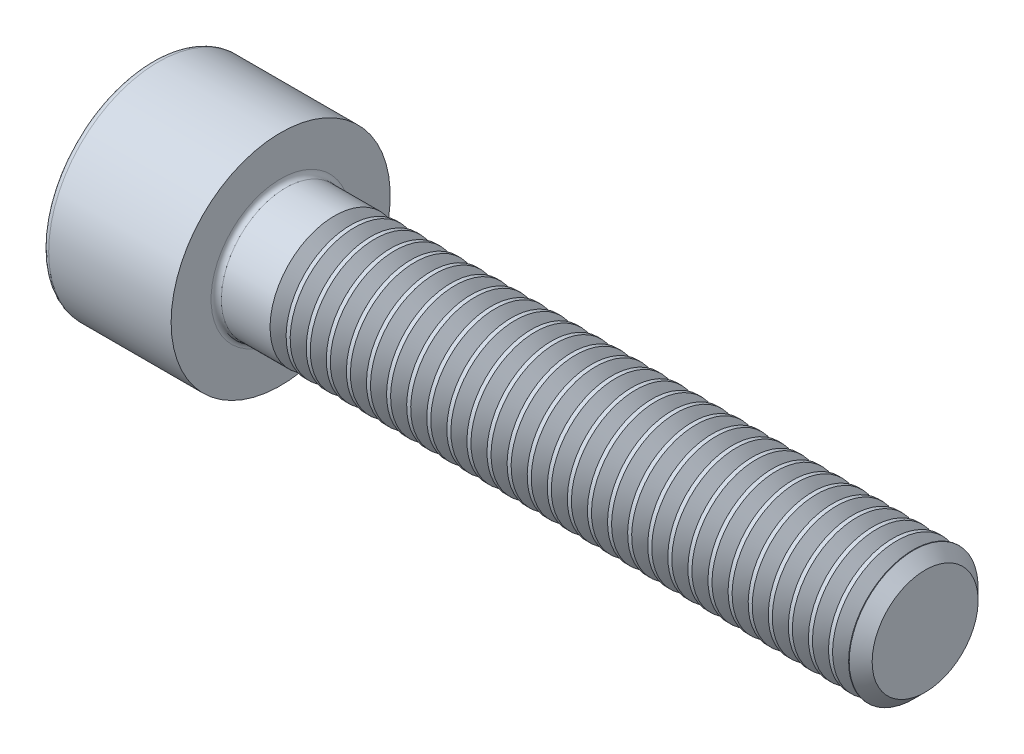
from build123d import *

# Parameters (mm, degrees)
FILLET1_R       = 0.2
FILLET2_R       = 0.25
HEX_2_DEPTH     = 2.5
THDSCHPAT_COUNT = 30
THDSCHPAT_PITCH = 0.779310345


with BuildPart() as part:
    # BodySke → Base-Revolve (revolve)
    with BuildSketch(Plane.XY):
        Polygon((0, 0), (0, 4.25), (5, 4.25), (5, 2.5), (29.555, 2.5), (30, 2.055), (30, 0), align=None)
    revolve(axis=Axis((-31.75, 0, 0), (1, 0, 0)))

    # Fillet1
    fillet1_edges = [part.edges().sort_by_distance(p)[0] for p in [
        (5, -2.5, 0),
    ]]
    fillet(fillet1_edges, radius=FILLET1_R)

    # Fillet2
    fillet2_edges = [part.edges().sort_by_distance(p)[0] for p in [
        (0, -4.25, 0),
    ]]
    fillet(fillet2_edges, radius=FILLET2_R)

    # Sketch2 → Hex-PreBroach (revolve, cut)
    with BuildSketch(Plane.XY):
        Polygon((0, 2.042), (2.5, 2.042), (3.67894925, 0), (0, 0), align=None)
    revolve(axis=Axis((0, 0, 0), (1, 0, 0)), mode=Mode.SUBTRACT)

    # Sketch3 → Hex 2 (cut)
    with BuildSketch(Plane(origin=(0, 0, 0), x_dir=(0, 0.5, 0.866025404), z_dir=(-1, 0, 0))):
        Polygon((1.17894925, 2.042), (-1.17894925, 2.042), (-2.357898499, 0), (-1.17894925, -2.042), (1.17894925, -2.042), (2.357898499, 0), align=None)
    extrude(amount=-HEX_2_DEPTH, mode=Mode.SUBTRACT)

    # ThdSchSke → ThreadSchematic (revolve, cut)
    with BuildSketch(Plane.XY):
        Polygon((7.4, -2.055), (7.088407645, -2.5), (7.088407645, -3.125), (7.711592355, -3.125), (7.711592355, -2.5), align=None)
    threadschematic = revolve(axis=Axis((-3.175, 0, 0), (1, 0, 0)), mode=Mode.SUBTRACT)

    # ThdSchPat: ThreadSchematic ×30
    with Locations(*[(i * THDSCHPAT_PITCH, 0, 0) for i in range(1, THDSCHPAT_COUNT)]):
        add(threadschematic, mode=Mode.SUBTRACT)


solid = part.part
